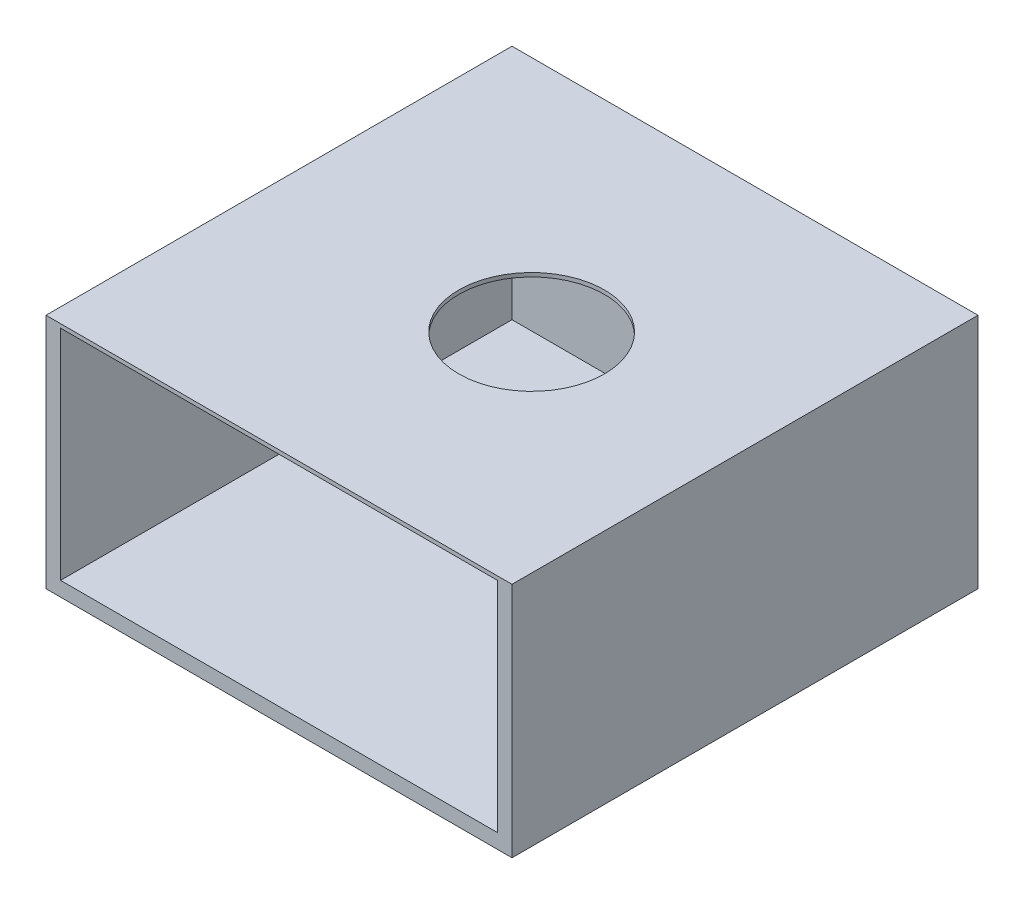
from build123d import *

# Parameters (mm, degrees)
SKETCH1_W           = 304.8
SKETCH1_H           = 152.4
BOSS_EXTRUDE1_DEPTH = 304.8
SHELL1_T            = -9.525
BOSS_EXTRUDE2_DEPTH = 2.54
SKETCH4_R           = 47.625
CUT_EXTRUDE1_DEPTH  = 7.62


with BuildPart() as part:
    # Sketch1 → Boss-Extrude1 (new body)
    with BuildSketch(Plane.XY):
        Rectangle(SKETCH1_W, SKETCH1_H)
    extrude(amount=BOSS_EXTRUDE1_DEPTH)

    # Shell1
    shell1_openings = [part.faces().sort_by_distance(p)[0] for p in [
        (0, 0, 304.8),
        (0, 76.2, 152.4),
    ]]
    offset(amount=SHELL1_T, openings=shell1_openings, kind=Kind.INTERSECTION)

    # Sketch2 → Boss-Extrude2 (add)
    with BuildSketch(Plane(origin=(0, 76.2, 0), x_dir=(1, 0, 0), z_dir=(0, 1, 0))):
        Polygon((-142.875, -304.8), (142.875, -304.8), (152.4, -304.8), (152.4, 0), (-152.4, 0), (-152.4, -304.8), align=None)
    extrude(amount=BOSS_EXTRUDE2_DEPTH)

    # Sketch4 → Cut-Extrude1 (cut)
    with BuildSketch(Plane(origin=(0, 78.74, 0), x_dir=(1, 0, 0), z_dir=(0, 1, 0))):
        with Locations((15.875, -155.428881859)):
            Circle(SKETCH4_R)
    extrude(amount=-CUT_EXTRUDE1_DEPTH, mode=Mode.SUBTRACT)


solid = part.part
